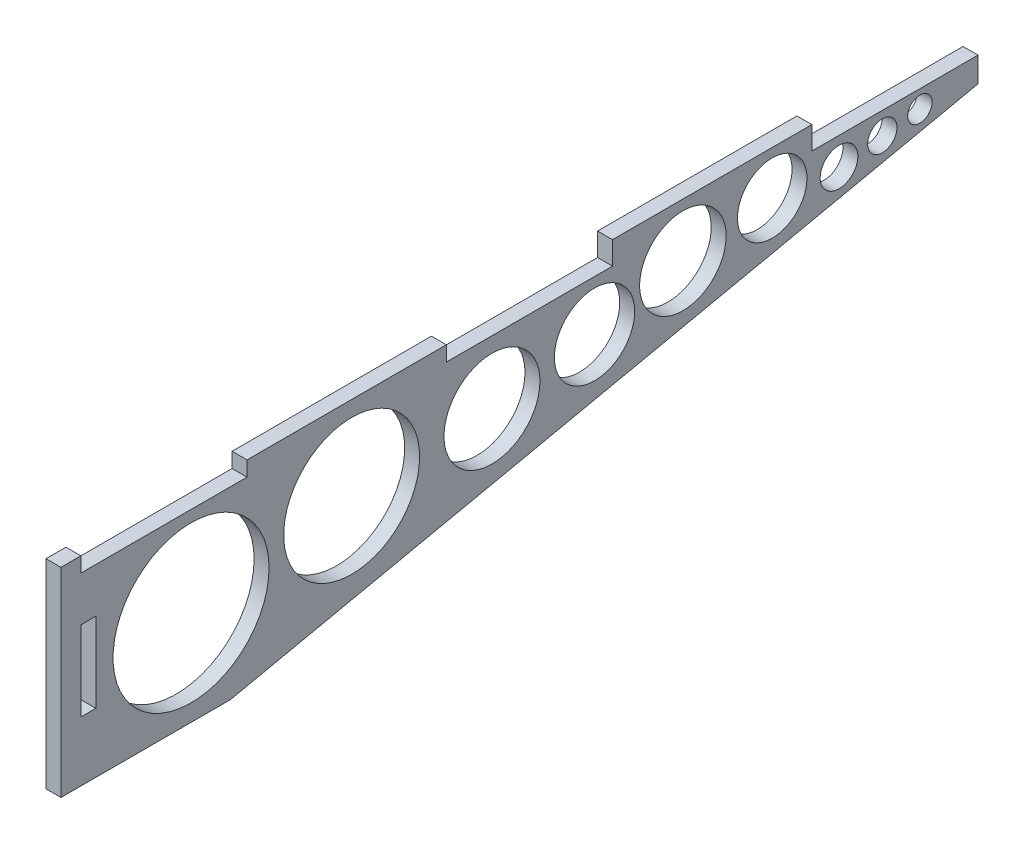
from build123d import *

# Parameters (mm, degrees)
SKETCH1_W           = 3
SKETCH1_H           = 16
BOSS_EXTRUDE1_DEPTH = 3
SKETCH2_W           = 40
SKETCH2_H           = 1.6
BOSS_EXTRUDE2_DEPTH = 3
SKETCH3_R           = 15.651050508
SKETCH3_R_2         = 13.636404617
SKETCH3_R_3         = 9.625367155
SKETCH3_R_4         = 8.055659383
SKETCH3_R_5         = 8.6792975
SKETCH3_R_6         = 6.974005881
SKETCH3_R_7         = 2.446418815
SKETCH3_R_8         = 3.779523595
SKETCH3_R_9         = 2.94345793
CUT_EXTRUDE1_DEPTH  = 10


with BuildPart() as part:
    # Sketch1 → Boss-Extrude1 (new body)
    with BuildSketch(Plane(origin=(0, 0, 0), x_dir=(0, 0, -1), z_dir=(1, 0, 0))):
        Polygon((30, -40), (180, -8), (180, -3), (146.666666667, -3), (146.666666667, 0), (106.666666667, 0), (106.666666667, -3), (73.333333333, -3), (73.333333333, 0), (33.333333333, 0), (33.333333333, -3), (0, -3), (0, 0), (-4, 0), (-4, -40), (0, -40), align=None)
        with Locations((1.5, -20)):
            Rectangle(SKETCH1_W, SKETCH1_H, mode=Mode.SUBTRACT)
    extrude(amount=BOSS_EXTRUDE1_DEPTH)

    # Sketch2 → Boss-Extrude2 (add)
    with BuildSketch(Plane(origin=(3, 0, 0), x_dir=(0, 0, -1), z_dir=(1, 0, 0))):
        with Locations((126.666666667, 0.8)):
            Rectangle(SKETCH2_W, SKETCH2_H)
    extrude(amount=-BOSS_EXTRUDE2_DEPTH)

    # Sketch3 → Cut-Extrude1 (cut)
    with BuildSketch(Plane(origin=(3, 0, 0), x_dir=(0, 0, -1), z_dir=(1, 0, 0))):
        with Locations((22.104563443, -20.956095071)):
            Circle(SKETCH3_R)
        with Locations((54.328943076, -16.752253971)):
            Circle(SKETCH3_R_2)
        with Locations((82.483117774, -15.673188709)):
            Circle(SKETCH3_R_3)
        with Locations((103.057816826, -13.060067591)):
            Circle(SKETCH3_R_4)
        with Locations((120.792027676, -9.128318411)):
            Circle(SKETCH3_R_5)
        with Locations((138.707850434, -7.192260379)):
            Circle(SKETCH3_R_6)
        with Locations((168.340077715, -6.548539538)):
            Circle(SKETCH3_R_7)
        with Locations((152.117415019, -8.502294699)):
            Circle(SKETCH3_R_8)
        with Locations((160.801244487, -7.420684272)):
            Circle(SKETCH3_R_9)
    extrude(amount=-CUT_EXTRUDE1_DEPTH, mode=Mode.SUBTRACT)


solid = part.part
